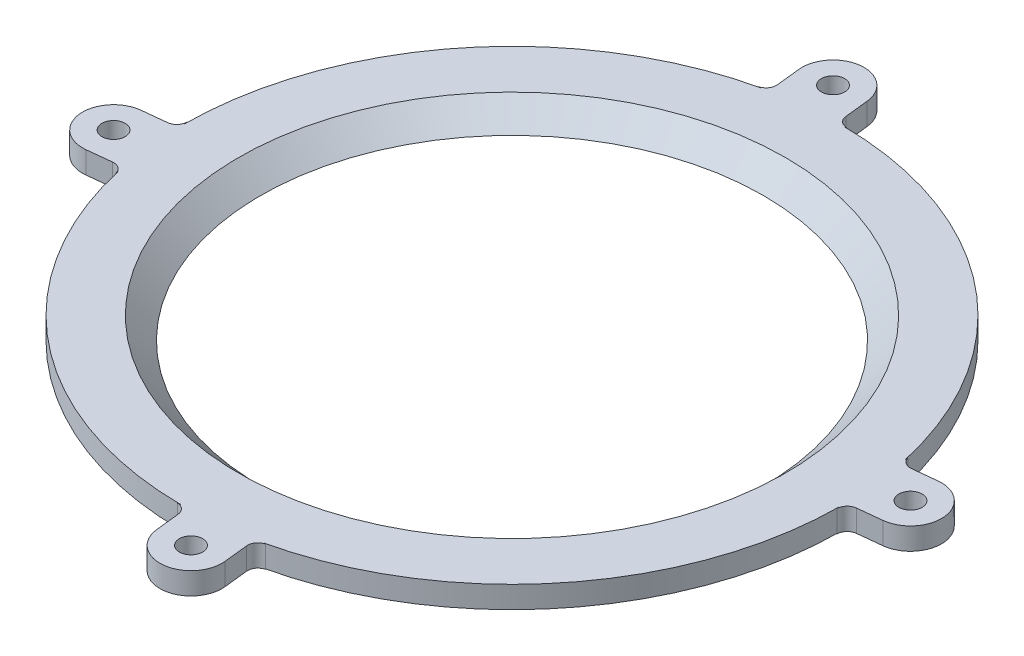
from build123d import *

# Parameters (mm, degrees)
FILLET1_R           = 2
FILLET2_R           = 6
SCALE1_SCALE        = 0.85
SKETCH4_R           = 10.6
CUT_EXTRUDE2_DEPTH  = 51.23590774
SKETCH9_R           = 2.25
BOSS_EXTRUDE1_DEPTH = 4.25
FILLET4_R           = 3
CUT_EXTRUDE3_DEPTH  = 46.98590774


with BuildPart() as part:
    # Sketch2 → Revolve1 (revolve)
    with BuildSketch(Plane(origin=(0, 0, 0), x_dir=(0, 0, -1), z_dir=(1, 0, 0))):
        Polygon((10.1, 0), (10.1, 6.971067812), (62.23, 59.101067812), (75, 59.101067812), (75, 54.101067812), (64.301067812, 54.101067812), (15.1, 4.9), (20, 0), align=None)
    revolve(axis=Axis((0, 0, 0), (0, 1, 0)))

    # Fillet1
    fillet1_edges = [part.edges().sort_by_distance(p)[0] for p in [
        (0, 4.9, 15.1),
    ]]
    fillet(fillet1_edges, radius=FILLET1_R)

    # Fillet2
    fillet2_edges = [part.edges().sort_by_distance(p)[0] for p in [
        (0, 6.971067812, 10.1),
    ]]
    fillet(fillet2_edges, radius=FILLET2_R)


with BuildPart() as part_1:
    # Scale1: scaled about (0, 40.216103787, 0)
    add(part.part.scale(SCALE1_SCALE).moved(Location((0, 6.032415568, 0))))

    # Sketch4 → Cut-Extrude2 (cut, through all)
    with BuildSketch(Plane.XZ.offset(-6.032415568)):
        Circle(SKETCH4_R)
    extrude(amount=-CUT_EXTRUDE2_DEPTH, mode=Mode.SUBTRACT)

    # Sketch9 → Boss-Extrude1 (add)
    with BuildSketch(Plane.XZ.offset(-52.018323208)):
        with BuildLine():
            Line((-62.154465971, 14.492663996), (-63.814937276, -0.932057036))
            ThreePointArc((-63.814937276, -0.932057036), (-64.336549414, 0.385954164), (-65.60066074, 1.027246064))
            Line((-65.60066074, 1.027246064), (-70.240082919, 1.526679887))
            ThreePointArc((-70.240082919, 1.526679887), (-75.563426885, 8.134403325), (-68.955703447, 13.45774729))
            Line((-68.955703447, 13.45774729), (-64.316281268, 12.958313466))
            ThreePointArc((-64.316281268, 12.958313466), (-62.944644221, 13.315867039), (-62.154465971, 14.492663996))
        make_face()
        with Locations((-69.597893183, 7.492213588)):
            Circle(SKETCH9_R, mode=Mode.SUBTRACT)
        with BuildLine():
            Line((-0.932057036, 63.814937276), (14.492663996, 62.154465971))
            ThreePointArc((14.492663996, 62.154465971), (13.315867039, 62.944644221), (12.958313466, 64.316281268))
            Line((12.958313466, 64.316281268), (13.45774729, 68.955703447))
            ThreePointArc((13.45774729, 68.955703447), (8.134403325, 75.563426885), (1.526679887, 70.240082919))
            Line((1.526679887, 70.240082919), (1.027246064, 65.60066074))
            ThreePointArc((1.027246064, 65.60066074), (0.385954164, 64.336549414), (-0.932057036, 63.814937276))
        make_face()
        with Locations((7.492213588, 69.597893183)):
            Circle(SKETCH9_R, mode=Mode.SUBTRACT)
        with BuildLine():
            Line((63.814937276, 0.932057036), (62.154465971, -14.492663996))
            ThreePointArc((62.154465971, -14.492663996), (62.944644221, -13.315867039), (64.316281268, -12.958313466))
            Line((64.316281268, -12.958313466), (68.955703447, -13.45774729))
            ThreePointArc((68.955703447, -13.45774729), (75.563426885, -8.134403325), (70.240082919, -1.526679887))
            Line((70.240082919, -1.526679887), (65.60066074, -1.027246064))
            ThreePointArc((65.60066074, -1.027246064), (64.336549414, -0.385954164), (63.814937276, 0.932057036))
        make_face()
        with Locations((69.597893183, -7.492213588)):
            Circle(SKETCH9_R, mode=Mode.SUBTRACT)
        with BuildLine():
            Line((-14.492663996, -62.154465971), (0.932057036, -63.814937276))
            ThreePointArc((0.932057036, -63.814937276), (-0.385954164, -64.336549414), (-1.027246064, -65.60066074))
            Line((-1.027246064, -65.60066074), (-1.526679887, -70.240082919))
            ThreePointArc((-1.526679887, -70.240082919), (-8.134403325, -75.563426885), (-13.45774729, -68.955703447))
            Line((-13.45774729, -68.955703447), (-12.958313466, -64.316281268))
            ThreePointArc((-12.958313466, -64.316281268), (-13.315867039, -62.944644221), (-14.492663996, -62.154465971))
        make_face()
        with Locations((-7.492213588, -69.597893183)):
            Circle(SKETCH9_R, mode=Mode.SUBTRACT)
    extrude(amount=-BOSS_EXTRUDE1_DEPTH)

    # Fillet4
    fillet4_edges = [part_1.edges().sort_by_distance(p)[0] for p in [
        (-7.495331881, 13.972823208, 7.495331881),
        (0, 52.018323208, 54.65590764),
    ]]
    fillet(fillet4_edges, radius=FILLET4_R)

    # Sketch11 → Cut-Extrude3 (cut, through all)
    with BuildSketch(Plane.XZ.offset(-52.018323208)):
        with BuildLine():
            Line((-62.220212975, 13.8819162), (-62.154465971, 14.492663996))
            ThreePointArc((-62.154465971, 14.492663996), (-62.944644221, 13.315867039), (-64.316281268, 12.958313466))
            Line((-64.316281268, 12.958313466), (-68.955703447, 13.45774729))
            ThreePointArc((-68.955703447, 13.45774729), (-75.563426885, 8.134403325), (-70.240082919, 1.526679887))
            Line((-70.240082919, 1.526679887), (-65.60066074, 1.027246064))
            ThreePointArc((-65.60066074, 1.027246064), (-64.336549414, 0.385954164), (-63.814937276, -0.932057036))
            Line((-63.814937276, -0.932057036), (-63.749190272, -0.321309239))
            ThreePointArc((-63.749190272, -0.321309239), (-49.643889291, -39.99433405), (-13.8819162, -62.220212975))
            Line((-13.8819162, -62.220212975), (-14.492663996, -62.154465971))
            ThreePointArc((-14.492663996, -62.154465971), (-13.315867039, -62.944644221), (-12.958313466, -64.316281268))
            Line((-12.958313466, -64.316281268), (-13.45774729, -68.955703447))
            ThreePointArc((-13.45774729, -68.955703447), (-8.134403325, -75.563426885), (-1.526679887, -70.240082919))
            Line((-1.526679887, -70.240082919), (-1.027246064, -65.60066074))
            ThreePointArc((-1.027246064, -65.60066074), (-0.385954164, -64.336549414), (0.932057036, -63.814937276))
            Line((0.932057036, -63.814937276), (0.321309239, -63.749190272))
            ThreePointArc((0.321309239, -63.749190272), (39.99433405, -49.643889291), (62.220212975, -13.8819162))
            Line((62.220212975, -13.8819162), (62.154465971, -14.492663996))
            ThreePointArc((62.154465971, -14.492663996), (62.944644221, -13.315867039), (64.316281268, -12.958313466))
            Line((64.316281268, -12.958313466), (68.955703447, -13.45774729))
            ThreePointArc((68.955703447, -13.45774729), (75.563426885, -8.134403325), (70.240082919, -1.526679887))
            Line((70.240082919, -1.526679887), (65.60066074, -1.027246064))
            ThreePointArc((65.60066074, -1.027246064), (64.336549414, -0.385954164), (63.814937276, 0.932057036))
            Line((63.814937276, 0.932057036), (63.749190272, 0.321309239))
            ThreePointArc((63.749190272, 0.321309239), (49.643889291, 39.99433405), (13.8819162, 62.220212975))
            Line((13.8819162, 62.220212975), (14.492663996, 62.154465971))
            ThreePointArc((14.492663996, 62.154465971), (13.315867039, 62.944644221), (12.958313466, 64.316281268))
            Line((12.958313466, 64.316281268), (13.45774729, 68.955703447))
            ThreePointArc((13.45774729, 68.955703447), (8.134403325, 75.563426885), (1.526679887, 70.240082919))
            Line((1.526679887, 70.240082919), (1.027246064, 65.60066074))
            ThreePointArc((1.027246064, 65.60066074), (0.385954164, 64.336549414), (-0.932057036, 63.814937276))
            Line((-0.932057036, 63.814937276), (-0.321309239, 63.749190272))
            ThreePointArc((-0.321309239, 63.749190272), (-39.99433405, 49.643889291), (-62.220212975, 13.8819162))
        make_face()
    extrude(amount=CUT_EXTRUDE3_DEPTH, mode=Mode.SUBTRACT)


solid = part_1.part
